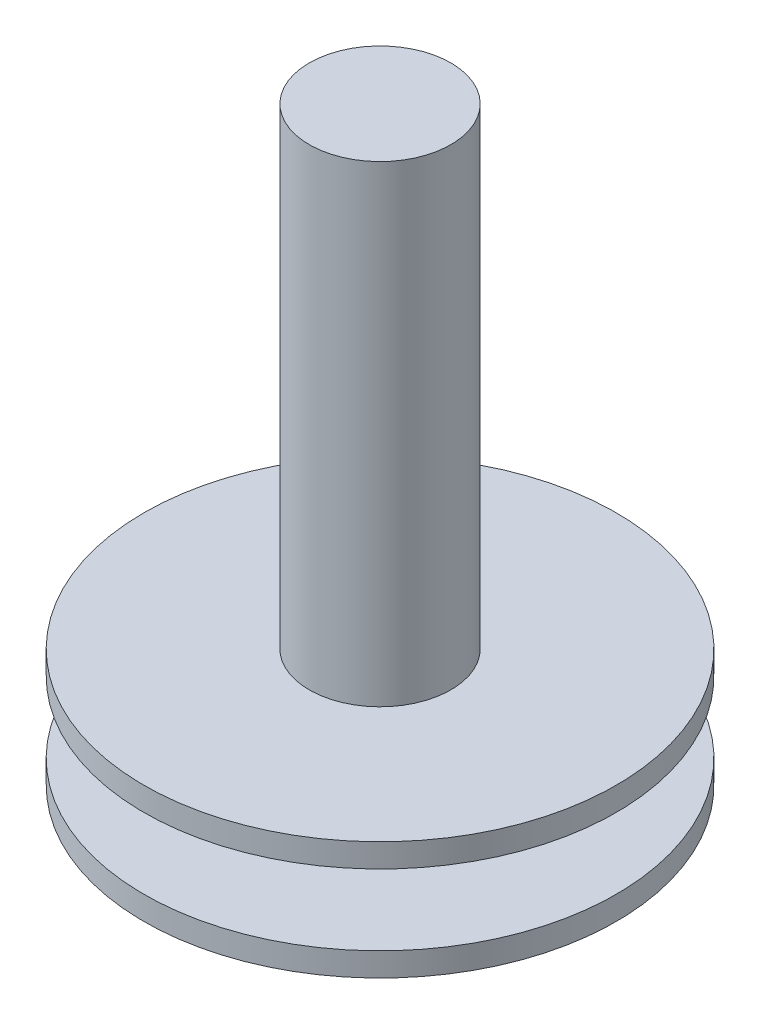
from build123d import *

# Parameters (mm, degrees)
SKETCH2_R           = 3
BOSS_EXTRUDE1_DEPTH = 20


with BuildPart() as part:
    # Sketch1 → Revolve1 (revolve)
    with BuildSketch(Plane.XY):
        Polygon((0, 0), (10, 0), (10, 1), (5, 1), (5, 4), (10, 4), (10, 5), (0, 5), align=None)
    revolve(axis=Axis((0, 5, 0), (0, -1, 0)))

    # Sketch2 → Boss-Extrude1 (add)
    with BuildSketch(Plane(origin=(0, 5, 0), x_dir=(1, 0, 0), z_dir=(0, 1, 0))):
        Circle(SKETCH2_R)
    extrude(amount=BOSS_EXTRUDE1_DEPTH)


solid = part.part
